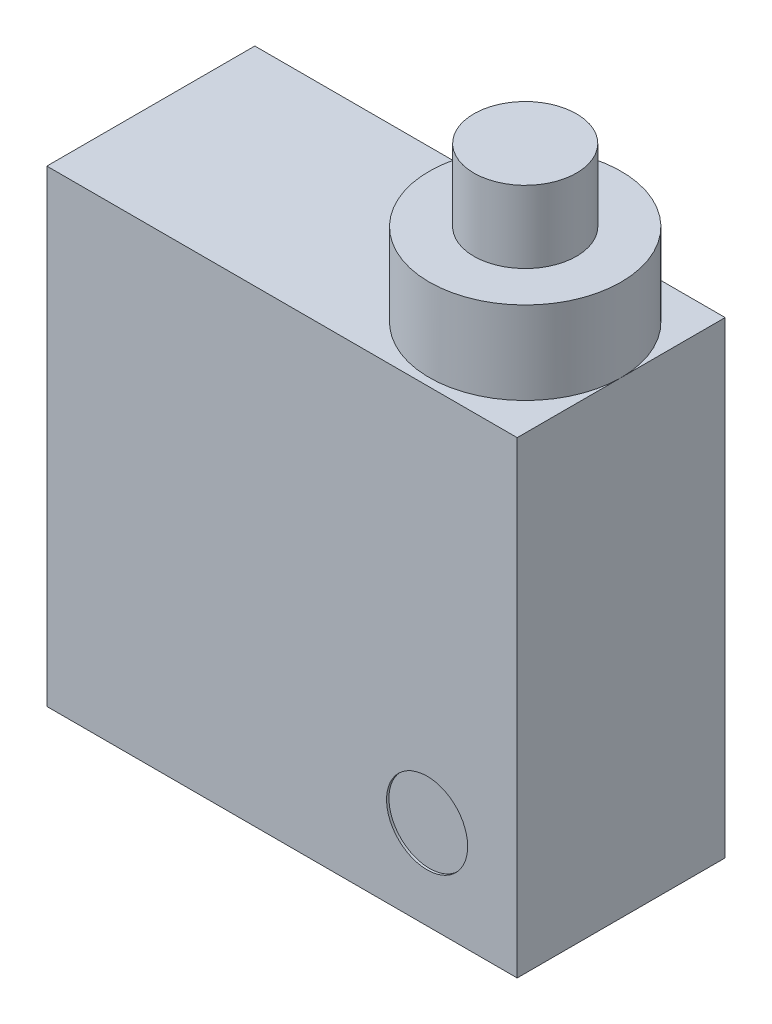
from build123d import *

# Parameters (mm, degrees)
SKETCH1_W           = 19.9
SKETCH1_H           = 8.8
BOSS_EXTRUDE1_DEPTH = 19.8
SKETCH2_R           = 2.172092228
BOSS_EXTRUDE2_DEPTH = 6.55
SKETCH3_R           = 4.06071901
BOSS_EXTRUDE3_DEPTH = 3.5
SKETCH4_R           = 1.716021907
CUT_EXTRUDE1_DEPTH  = 0.1


with BuildPart() as part:
    # Sketch1 → Boss-Extrude1 (new body)
    with BuildSketch(Plane(origin=(0, 0, 0), x_dir=(1, 0, 0), z_dir=(0, 1, 0))):
        with Locations((9.95, 4.4)):
            Rectangle(SKETCH1_W, SKETCH1_H)
    extrude(amount=BOSS_EXTRUDE1_DEPTH)

    # Sketch2 → Boss-Extrude2 (add)
    with BuildSketch(Plane(origin=(0, 19.8, 0), x_dir=(1, 0, 0), z_dir=(0, 1, 0))):
        with Locations((15.83928099, 4.4)):
            Circle(SKETCH2_R)
    extrude(amount=BOSS_EXTRUDE2_DEPTH)

    # Sketch3 → Boss-Extrude3 (add)
    with BuildSketch(Plane(origin=(0, 19.8, 0), x_dir=(1, 0, 0), z_dir=(0, 1, 0))):
        with Locations((15.83928099, 4.4)):
            Circle(SKETCH3_R)
    extrude(amount=BOSS_EXTRUDE3_DEPTH)

    # Sketch4 → Cut-Extrude1 (cut)
    with BuildSketch(Plane.XY):
        with Locations((16.089426616, 3.774002994)):
            Circle(SKETCH4_R)
    extrude(amount=-CUT_EXTRUDE1_DEPTH, mode=Mode.SUBTRACT)


solid = part.part
